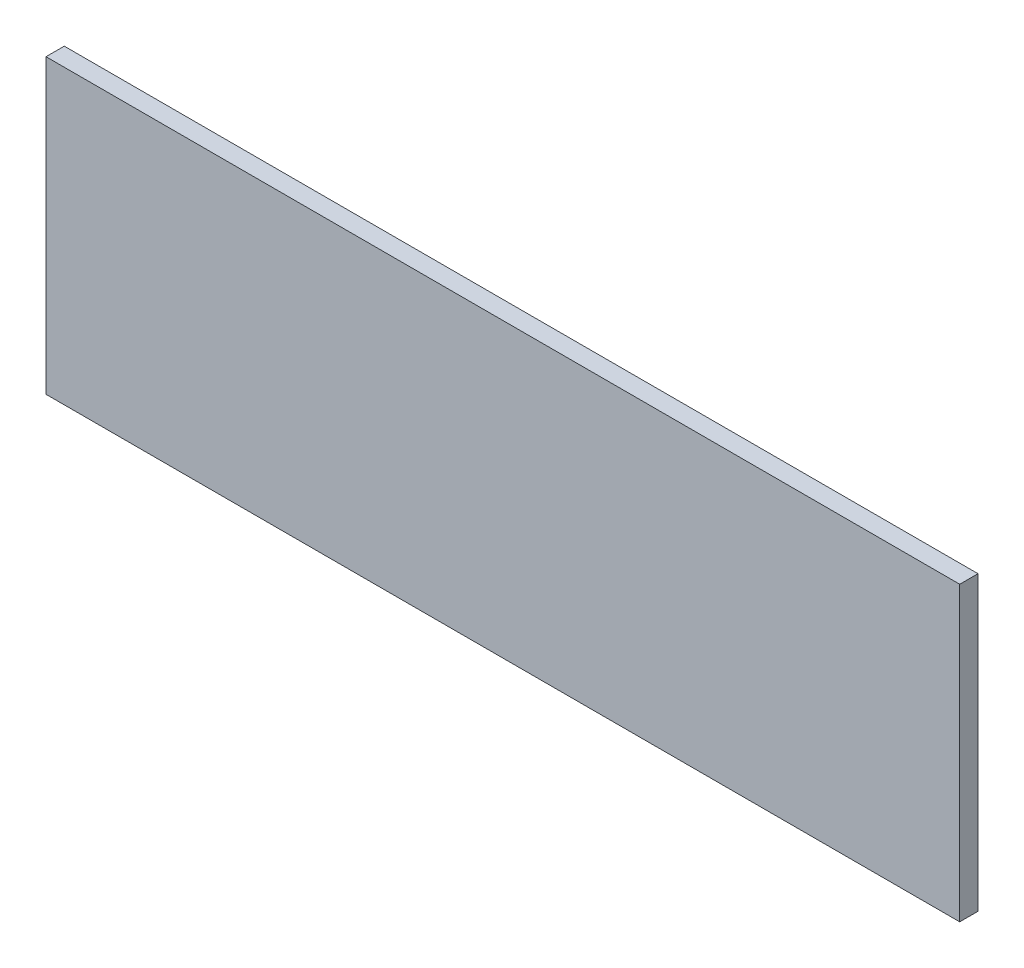
from build123d import *

# Parameters (mm, degrees)
SKETCH1_W           = 635
SKETCH1_H           = 203.2
BOSS_EXTRUDE1_DEPTH = 12.7


with BuildPart() as part:
    # Sketch1 → Boss-Extrude1 (new body)
    with BuildSketch(Plane.XY):
        Rectangle(SKETCH1_W, SKETCH1_H)
    extrude(amount=BOSS_EXTRUDE1_DEPTH)


solid = part.part
